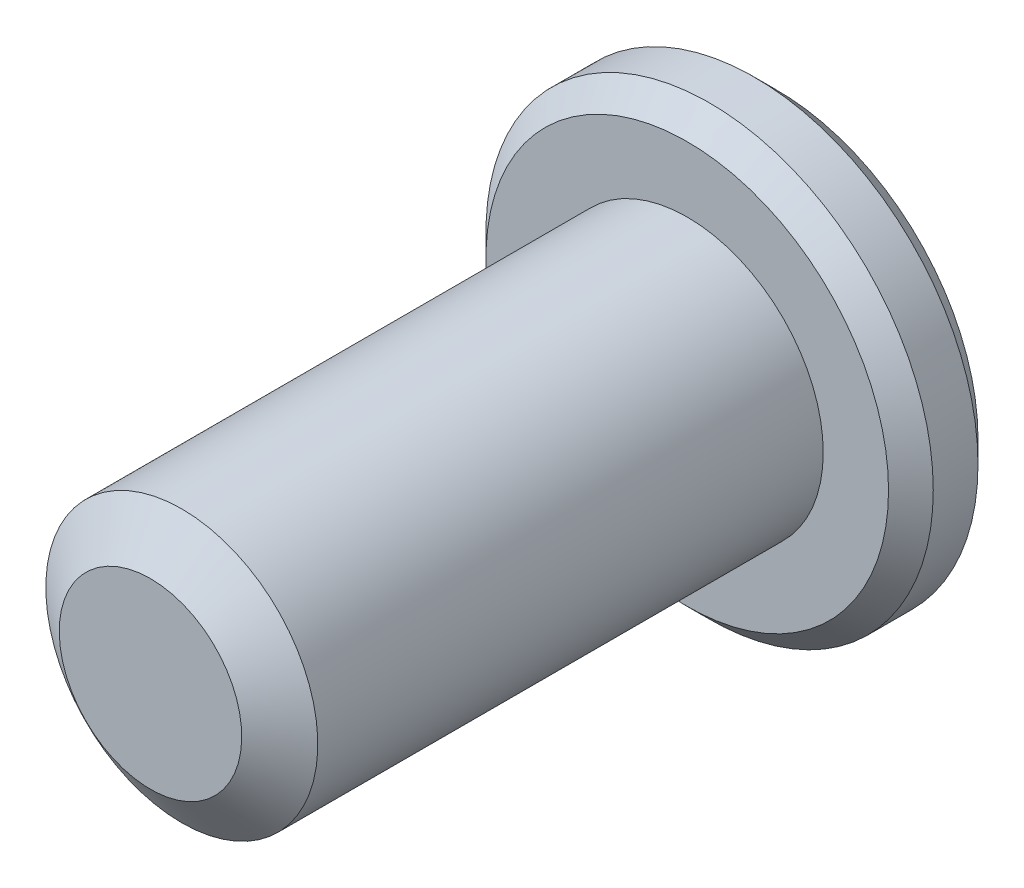
from build123d import *

# Parameters (mm, degrees)
SKETCH1_R          = 2.413
EXTRUDE1_DEPTH     = 11.1125
SKETCH6_R          = 3.96875
EXTRUDE2_DEPTH     = 1.5875
CUT_EXTRUDE1_DEPTH = 1.190625
SKETCH8_R          = 1.374815329
CUT_EXTRUDE2_DEPTH = 1.190625
CUT_EXTRUDE2_TAPER = 45
CHAMFER1_SIZE      = 0.396875


with BuildPart() as part:
    # Sketch1 → Extrude1 (new body)
    with BuildSketch(Plane.XY):
        Circle(SKETCH1_R)
    extrude(amount=EXTRUDE1_DEPTH)

    # Sketch4 → Cut-Revolve1 (revolve, cut)
    with BuildSketch(Plane(origin=(0, 0, 0), x_dir=(0, 0, -1), z_dir=(1, 0, 0))):
        Polygon((-10.556710267, 2.413), (-11.1125, 1.61925), (-11.1125, 2.413), align=None)
    revolve(axis=Axis((0, 0, 0), (0, 0, 1)), mode=Mode.SUBTRACT)

    # Sketch6 → Extrude2 (add)
    with BuildSketch(Plane.XY):
        Circle(SKETCH6_R)
    extrude(amount=EXTRUDE2_DEPTH)

    # Sketch7 → Cut-Extrude1 (cut)
    with BuildSketch(Plane.XY):
        Polygon((0, 1.374815329), (-1.190625, 0.687407664), (-1.190625, -0.687407664), (0, -1.374815329), (1.190625, -0.687407664), (1.190625, 0.687407664), align=None)
    extrude(amount=CUT_EXTRUDE1_DEPTH, mode=Mode.SUBTRACT)

    # Sketch8 → Cut-Extrude2 (cut)
    with BuildSketch(Plane.XY):
        Circle(SKETCH8_R)
    extrude(amount=CUT_EXTRUDE2_DEPTH, taper=CUT_EXTRUDE2_TAPER, mode=Mode.SUBTRACT)

    # Chamfer1
    chamfer1_edges = [part.edges().sort_by_distance(p)[0] for p in [
        (-3.96875, 0, 1.5875),
        (-3.96875, 0, 0),
    ]]
    chamfer(chamfer1_edges, length=CHAMFER1_SIZE)


solid = part.part
